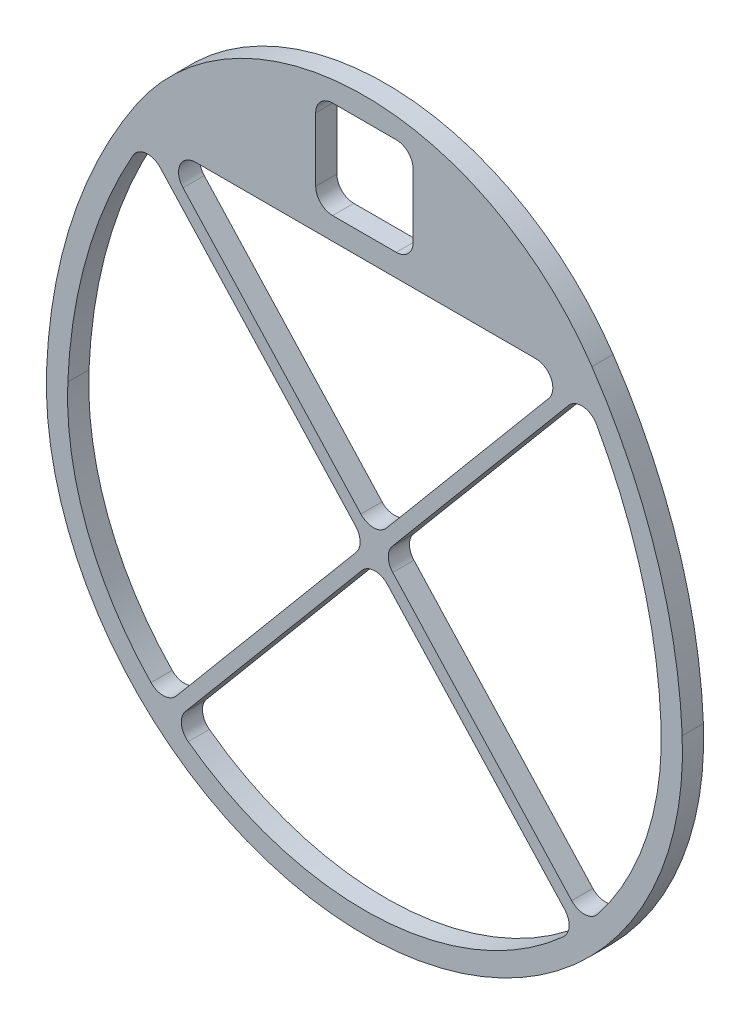
from build123d import *

# Parameters (mm, degrees)
BOSS_EXTRUDE1_DEPTH = 6.35
CUT_EXTRUDE1_REACH  = 8.35
SKETCH2_W           = 29.21
SKETCH2_H           = 29.21
FILLET1_R           = 5.08
BOSS_EXTRUDE2_DEPTH = 6.35
FILLET2_R           = 5.08


with BuildPart() as part:
    # Sketch1 → Boss-Extrude1 (new body)
    with BuildSketch(Plane.XY):
        with BuildLine():
            ThreePointArc((-68.188405154, 82.55), (-87.437503618, 43.287282526), (-95.244575115, 0.262424481))
            ThreePointArc((-95.244575115, 0.262424481), (0, -99.003097439), (95.244575115, 0.262424481))
            ThreePointArc((95.244575115, 0.262424481), (87.437503618, 43.287282526), (68.188405154, 82.55))
            ThreePointArc((68.188405154, 82.55), (0, 118.781058361), (-68.188405154, 82.55))
        make_face()
        with BuildLine():
            Line((-64.77, 76.2), (64.77, 76.2))
            ThreePointArc((64.77, 76.2), (81.91955238, 39.710108254), (88.9, 0))
            ThreePointArc((88.9, 0), (0, -92.653098722), (-88.9, 0))
            ThreePointArc((-88.9, 0), (-81.91955238, 39.710108254), (-64.77, 76.2))
        make_face(mode=Mode.SUBTRACT)
    extrude(amount=BOSS_EXTRUDE1_DEPTH)

    # Sketch2 → Cut-Extrude1 (cut, up to next)
    with BuildSketch(Plane.XY.offset(6.35), mode=Mode.PRIVATE) as cut_extrude1_sk1:
        with Locations((0, 97.49052918)):
            Rectangle(SKETCH2_W, SKETCH2_H)
    cut_extrude1_tool1 = extrude(cut_extrude1_sk1.sketch, amount=-CUT_EXTRUDE1_REACH, mode=Mode.PRIVATE) & part.part
    add(cut_extrude1_tool1.solids().sort_by_distance((0, 97.490529, 6.35))[0], mode=Mode.SUBTRACT)

    # Fillet1
    fillet1_edges = [part.edges().sort_by_distance(p)[0] for p in [
        (14.605, 112.09552918, 3.175),
        (14.605, 82.88552918, 3.175),
        (-14.605, 82.88552918, 3.175),
        (-14.605, 112.09552918, 3.175),
    ]]
    fillet(fillet1_edges, radius=FILLET1_R)

    # Sketch3 → Boss-Extrude2 (add)
    with BuildSketch(Plane.XY.offset(6.35)):
        with BuildLine():
            ThreePointArc((-64.77, 76.2), (-65.301178837, 75.369054935), (-65.826969345, 74.534689907))
            Line((-65.826969345, 74.534689907), (0.397744119, 2.447786681))
            Line((0.397744119, 2.447786681), (2.867484972, 5.391109215))
            Line((2.867484972, 5.391109215), (-62.183145491, 76.2))
            Line((-62.183145491, 76.2), (-64.77, 76.2))
        make_face()
        with BuildLine():
            Line((62.283199114, 76.2), (2.867484972, 5.391109215))
            Line((2.867484972, 5.391109215), (5.466869825, 2.561627672))
            Line((5.466869825, 2.561627672), (65.84083728, 74.512520285))
            ThreePointArc((65.84083728, 74.512520285), (65.308184865, 75.358015528), (64.77, 76.2))
            Line((64.77, 76.2), (62.283199114, 76.2))
        make_face()
        with BuildLine():
            Line((5.466869825, 2.561627672), (2.997128973, -0.381694862))
            Line((2.997128973, -0.381694862), (63.387167907, -66.117440095))
            ThreePointArc((63.387167907, -66.117440095), (64.712838285, -64.7424562), (66.008689372, -63.339333743))
            Line((66.008689372, -63.339333743), (5.466869825, 2.561627672))
        make_face()
        Polygon((2.867484972, 5.391109215), (0.397744119, 2.447786681), (2.997128973, -0.381694862), (5.466869825, 2.561627672), align=None)
        with BuildLine():
            Line((2.997128973, -0.381694862), (0.397744119, 2.447786681))
            Line((0.397744119, 2.447786681), (-59.927506787, -69.445047811))
            ThreePointArc((-59.927506787, -69.445047811), (-58.505389643, -70.713272134), (-57.056440469, -71.950751993))
            Line((-57.056440469, -71.950751993), (2.997128973, -0.381694862))
        make_face()
    extrude(amount=-BOSS_EXTRUDE2_DEPTH)

    # Fillet2
    fillet2_edges = [part.edges().sort_by_distance(p)[0] for p in [
        (0.397744119, 2.447786681, 3.175),
        (-65.826969345, 74.534689907, 3.175),
        (-62.183145491, 76.2, 3.175),
        (2.867484972, 5.391109215, 3.175),
        (62.283199114, 76.2, 3.175),
        (65.84083728, 74.512520285, 3.175),
        (5.466869825, 2.561627672, 3.175),
        (66.008689372, -63.339333743, 3.175),
        (63.387167907, -66.117440095, 3.175),
        (2.997128973, -0.381694862, 3.175),
        (-57.056440469, -71.950751993, 3.175),
        (-59.927506787, -69.445047811, 3.175),
    ]]
    fillet(fillet2_edges, radius=FILLET2_R)


solid = part.part
